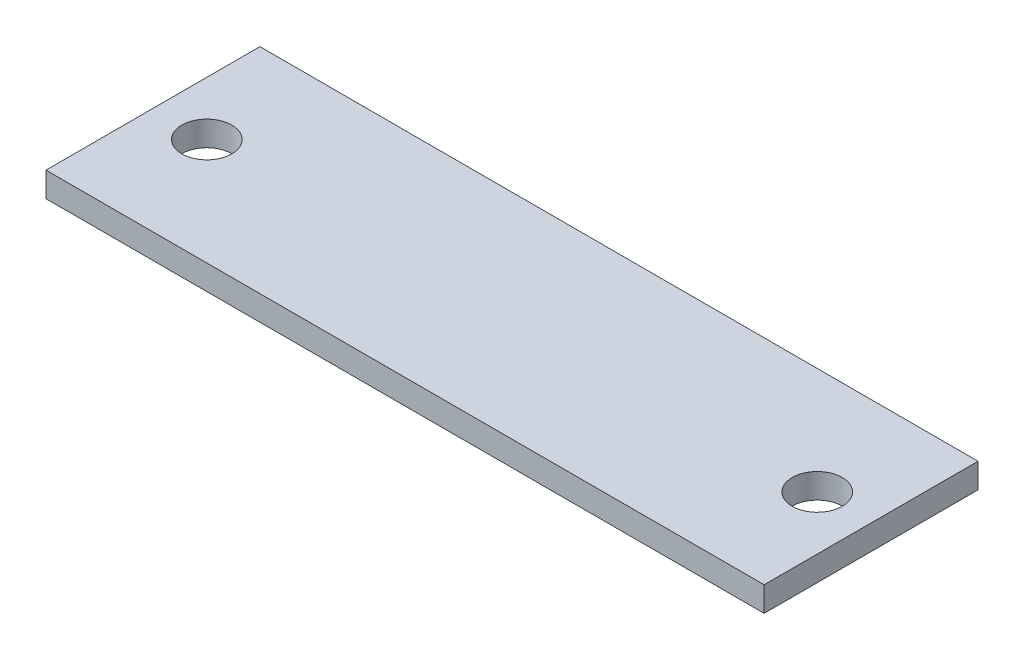
from build123d import *

# Parameters (mm, degrees)
SKETCH1_W           = 45.999999948
SKETCH1_H           = 13.700000032
SKETCH1_R           = 1.599999975
BOSS_EXTRUDE1_DEPTH = 0.79375


with BuildPart() as part:
    # Sketch1 → Boss-Extrude1 (new body, symmetric)
    with BuildSketch(Plane(origin=(0, 0, 0), x_dir=(1, 0, 0), z_dir=(0, 1, 0))):
        Rectangle(SKETCH1_W, SKETCH1_H)
        with Locations((-19.550000016, 0)):
            Circle(SKETCH1_R, mode=Mode.SUBTRACT)
        with Locations((19.550000016, 0)):
            Circle(SKETCH1_R, mode=Mode.SUBTRACT)
    extrude(amount=BOSS_EXTRUDE1_DEPTH, both=True)


solid = part.part
